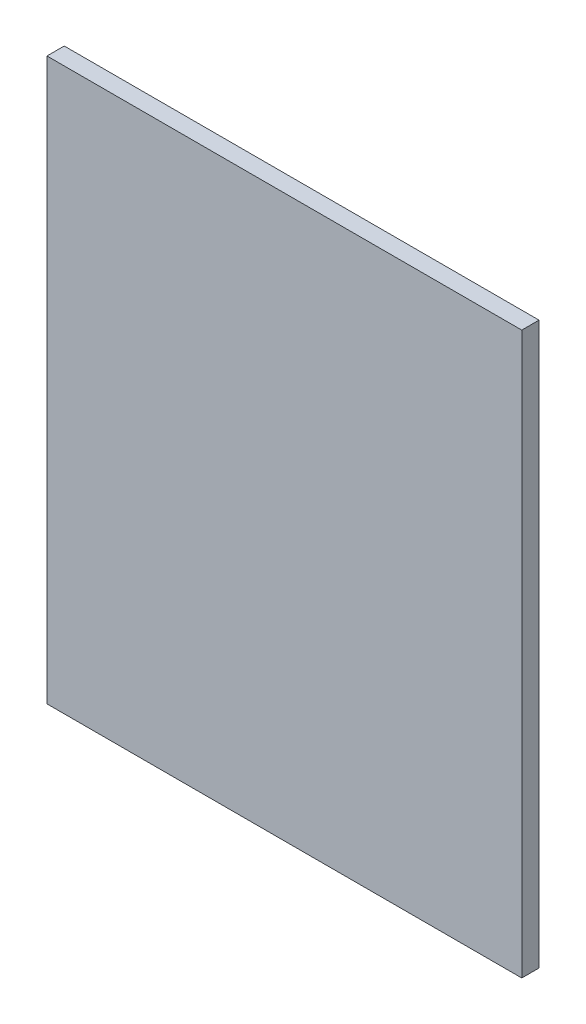
from build123d import *

# Parameters (mm, degrees)
SKETCH_1_W      = 550
SKETCH_1_H      = 650
EXTRUDE_1_DEPTH = 20


with BuildPart() as part:
    # 草图1 → 凸台-拉伸1 (new body)
    with BuildSketch(Plane.XY):
        Rectangle(SKETCH_1_W, SKETCH_1_H)
    extrude(amount=EXTRUDE_1_DEPTH)


solid = part.part
